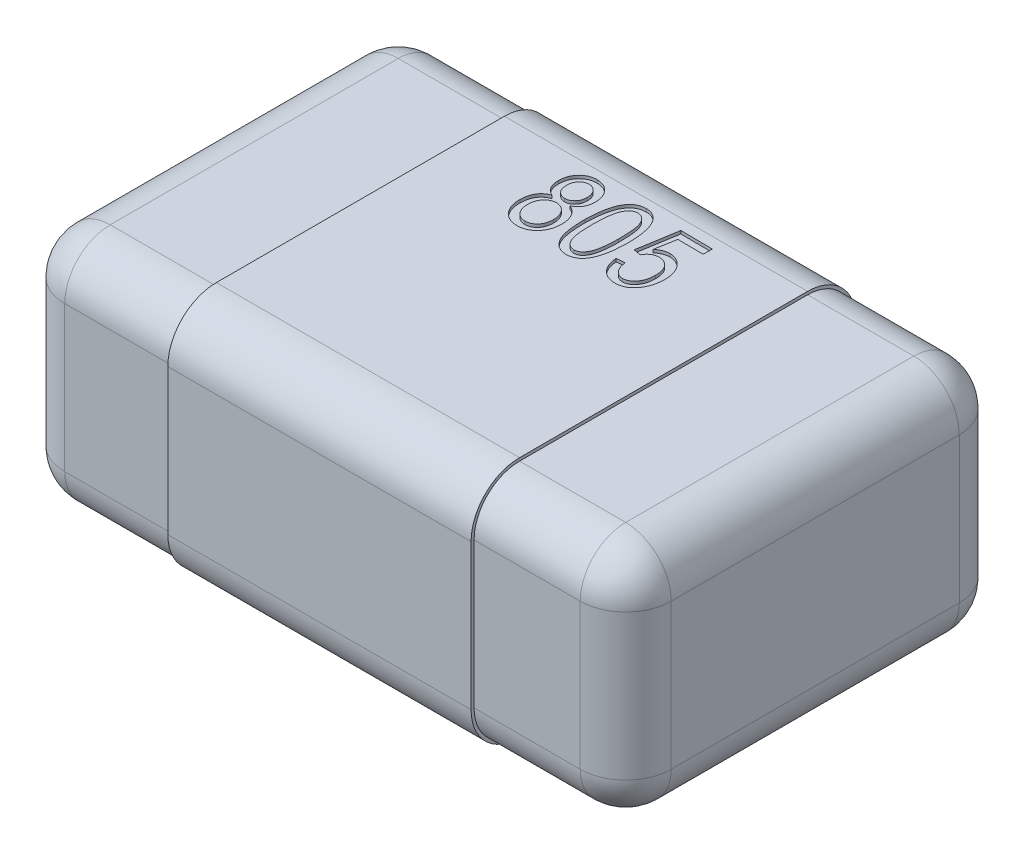
from build123d import *

# Parameters (mm, degrees)
ESBO_O1_W                     = 2
ESBO_O1_H                     = 1.25
RESSALTO_EXTRUS_O1_DEPTH      = 0.78
FILETE1_R                     = 0.15
RESSALTO_EXTRUS_O4_DEPTH      = 0.5
RESSALTO_EXTRUS_O4_DEPTH_BACK = 0.5
CORTE_EXTRUS_O1_DEPTH         = 0.01


with BuildPart() as part:
    # Esboço1 → Ressalto-extrusão1 (new body)
    with BuildSketch(Plane(origin=(0, 0.78, 0), x_dir=(1, 0, 0), z_dir=(0, 1, 0))):
        Rectangle(ESBO_O1_W, ESBO_O1_H)
    extrude(amount=-RESSALTO_EXTRUS_O1_DEPTH)

    # Filete1
    filete1_edges = [part.edges().sort_by_distance(p)[0] for p in [
        (1, 0, 0),
        (0, 0, -0.625),
        (-1, 0, 0),
        (0, 0.78, -0.625),
        (1, 0.78, 0),
        (0, 0.78, 0.625),
        (-1, 0.78, 0),
        (0, 0, 0.625),
        (-1, 0.39, -0.625),
        (1, 0.39, -0.625),
        (1, 0.39, 0.625),
        (-1, 0.39, 0.625),
    ]]
    fillet(filete1_edges, radius=FILETE1_R)

    # Esboço4 → Ressalto-extrusão4 (add, two sides)
    with BuildSketch(Plane(origin=(0, 0, 0), x_dir=(0, 0, -1), z_dir=(1, 0, 0))) as ressalto_extrus_o4_sk:
        with BuildLine():
            Line((0.635, 0.15), (0.635, 0.63))
            ThreePointArc((0.635, 0.63), (0.588137085, 0.743137085), (0.475, 0.79))
            Line((0.475, 0.79), (-0.475, 0.79))
            ThreePointArc((-0.475, 0.79), (-0.588137085, 0.743137085), (-0.635, 0.63))
            Line((-0.635, 0.63), (-0.635, 0.15))
            ThreePointArc((-0.635, 0.15), (-0.588137085, 0.036862915), (-0.475, -0.01))
            Line((-0.475, -0.01), (0.475, -0.01))
            ThreePointArc((0.475, -0.01), (0.588137085, 0.036862915), (0.635, 0.15))
        make_face()
        with BuildLine():
            Line((0.625, 0.15), (0.625, 0.63))
            ThreePointArc((0.625, 0.63), (0.581066017, 0.736066017), (0.475, 0.78))
            Line((0.475, 0.78), (-0.475, 0.78))
            ThreePointArc((-0.475, 0.78), (-0.581066017, 0.736066017), (-0.625, 0.63))
            Line((-0.625, 0.63), (-0.625, 0.15))
            ThreePointArc((-0.625, 0.15), (-0.581066017, 0.043933983), (-0.475, 0))
            Line((-0.475, 0), (0.475, 0))
            ThreePointArc((0.475, 0), (0.581066017, 0.043933983), (0.625, 0.15))
        make_face(mode=Mode.SUBTRACT)
    extrude(amount=RESSALTO_EXTRUS_O4_DEPTH)
    extrude(ressalto_extrus_o4_sk.sketch, amount=-RESSALTO_EXTRUS_O4_DEPTH_BACK)

    # Esboço2 → Corte-extrusão1 (cut)
    with BuildSketch(Plane(origin=(0, 0.79, 0), x_dir=(0, 0, 1), z_dir=(0, -1, 0))):
        with BuildLine():
            Line((-0.253066861, -0.090329898), (-0.255669833, -0.117584099))
            add(Edge.make_bspline(
                [(-0.255669833, -0.117584099), (-0.253681074, -0.117861542), (-0.249809014, -0.118401717), (-0.244214534, -0.119491466), (-0.239012719, -0.120846537), (-0.234225636, -0.122506374), (-0.229794502, -0.12432543), (-0.22576998, -0.126468531), (-0.22210853, -0.128835246), (-0.218891368, -0.131518493), (-0.216004401, -0.134334812), (-0.213518025, -0.13730113), (-0.211385032, -0.140378806), (-0.209679505, -0.143577329), (-0.20828577, -0.146879121), (-0.207291732, -0.150287825), (-0.206693548, -0.15383074), (-0.206601805, -0.15622493), (-0.206555161, -0.157442196)],
                knots=[0, 0, 0, 0, 1.38702458, 2.700499694, 3.935238579, 5.096953292, 6.198529759, 7.240644087, 8.242594165, 9.204574647, 10.129612427, 11.025542709, 11.874335218, 12.711681274, 13.525120647, 14.346138538, 15.159135127, 16, 16, 16, 16], degree=3))
            add(Edge.make_bspline(
                [(-0.206555161, -0.157442196), (-0.20659514, -0.158958341), (-0.206674321, -0.161961136), (-0.207460742, -0.166387154), (-0.208751993, -0.170659263), (-0.210549102, -0.174794271), (-0.213001017, -0.178711941), (-0.215888261, -0.182527474), (-0.219371222, -0.186133297), (-0.223293172, -0.189590506), (-0.22772585, -0.192712782), (-0.232519424, -0.195534316), (-0.237749111, -0.197864637), (-0.243353893, -0.199776731), (-0.249343489, -0.201283736), (-0.255719225, -0.202375207), (-0.262482319, -0.203072583), (-0.267129123, -0.203194089), (-0.269509575, -0.203256334)],
                knots=[0, 0, 0, 0, 0.839665796, 1.662997701, 2.482096218, 3.309247666, 4.153318297, 5.037512989, 5.956665417, 6.926897057, 7.931076711, 8.956993583, 10.005081474, 11.098198013, 12.235579651, 13.424411873, 14.680584685, 16, 16, 16, 16], degree=3))
            add(Edge.make_bspline(
                [(-0.269509575, -0.203256334), (-0.271753281, -0.20324228), (-0.276112071, -0.203214979), (-0.282457423, -0.202613172), (-0.288424533, -0.201713754), (-0.294010782, -0.200339346), (-0.29922007, -0.198574388), (-0.304023268, -0.196331862), (-0.308485604, -0.193772035), (-0.312493222, -0.190741776), (-0.316073741, -0.187447202), (-0.319208481, -0.183902384), (-0.321880479, -0.180168305), (-0.324056377, -0.176195234), (-0.325757183, -0.172027544), (-0.326968803, -0.167657526), (-0.327756799, -0.163075828), (-0.327876595, -0.159947275), (-0.327937864, -0.158347196)],
                knots=[0, 0, 0, 0, 1.301078701, 2.527572645, 3.69404768, 4.798991284, 5.860664038, 6.879371706, 7.869767973, 8.839435854, 9.787494005, 10.688249472, 11.579995176, 12.445557477, 13.310239216, 14.185371191, 15.071919164, 16, 16, 16, 16], degree=3))
            add(Edge.make_bspline(
                [(-0.327937864, -0.158347196), (-0.327875614, -0.156409781), (-0.327751398, -0.152543796), (-0.326476977, -0.146858963), (-0.324488116, -0.14133763), (-0.321634889, -0.136095193), (-0.318101728, -0.131170479), (-0.313780077, -0.126810592), (-0.308871141, -0.122912338), (-0.305196963, -0.120827116), (-0.303326113, -0.119765344)],
                knots=[0, 0, 0, 0, 0.96398326, 1.923564835, 2.888092038, 3.880191464, 4.887766155, 5.89771773, 6.92954116, 8, 8, 8, 8], degree=3))
            Line((-0.303326113, -0.119765344), (-0.307397337, -0.095389431))
            Line((-0.307397337, -0.095389431), (-0.439625822, -0.117123791))
            Line((-0.439625822, -0.117123791), (-0.438743876, -0.222139743))
            Line((-0.438743876, -0.222139743), (-0.408516123, -0.221876443))
            Line((-0.408516123, -0.221876443), (-0.409247039, -0.137603498))
            Line((-0.409247039, -0.137603498), (-0.340025673, -0.125561783))
            add(Edge.make_bspline(
                [(-0.340025673, -0.125561783), (-0.341311262, -0.127126592), (-0.3438334, -0.130196518), (-0.347086448, -0.135075395), (-0.349828763, -0.140021801), (-0.352037523, -0.145040852), (-0.353801419, -0.150082451), (-0.355025921, -0.155201424), (-0.355731626, -0.160402823), (-0.355813204, -0.16390113), (-0.355854206, -0.16565939)],
                knots=[0, 0, 0, 0, 1.102656858, 2.163251155, 3.189163745, 4.179949051, 5.146946918, 6.094910201, 7.042495509, 8, 8, 8, 8], degree=3))
            add(Edge.make_bspline(
                [(-0.355854206, -0.16565939), (-0.355760944, -0.167833298), (-0.355576404, -0.172134883), (-0.354447416, -0.178485838), (-0.35261918, -0.184606482), (-0.350099509, -0.190515981), (-0.346844388, -0.196174272), (-0.342858116, -0.201585317), (-0.338200786, -0.206796897), (-0.332881538, -0.211737158), (-0.326936504, -0.216239312), (-0.320506632, -0.220236385), (-0.313526788, -0.223481706), (-0.306131227, -0.22627122), (-0.298181016, -0.228268818), (-0.289780338, -0.229754707), (-0.280891611, -0.23059709), (-0.274805976, -0.23063847), (-0.271692966, -0.230659637)],
                knots=[0, 0, 0, 0, 0.880322538, 1.741924456, 2.603842194, 3.462077736, 4.337326652, 5.24094951, 6.178675148, 7.163753722, 8.175594835, 9.194211038, 10.222930267, 11.287579889, 12.390110003, 13.536557808, 14.739865404, 16, 16, 16, 16], degree=3))
            add(Edge.make_bspline(
                [(-0.271692966, -0.230659637), (-0.26859965, -0.230582317), (-0.262505139, -0.23042998), (-0.253549726, -0.22941805), (-0.244930876, -0.227823564), (-0.236668372, -0.225568888), (-0.228700479, -0.222815057), (-0.221139258, -0.219292778), (-0.213879389, -0.215275333), (-0.207065671, -0.210642725), (-0.200813728, -0.205536019), (-0.195317889, -0.199940945), (-0.190724738, -0.193889686), (-0.18690889, -0.187456738), (-0.184005134, -0.180580521), (-0.181913678, -0.173287056), (-0.18075483, -0.165571155), (-0.180613696, -0.160298462), (-0.180541917, -0.157616818)],
                knots=[0, 0, 0, 0, 1.138249842, 2.242601474, 3.312534934, 4.360702407, 5.391748649, 6.410873498, 7.426241692, 8.442273835, 9.438707846, 10.392558326, 11.321114167, 12.227868366, 13.137929477, 14.060125271, 15.013397121, 16, 16, 16, 16], degree=3))
            add(Edge.make_bspline(
                [(-0.180541917, -0.157616818), (-0.18062612, -0.155374401), (-0.180791873, -0.150960245), (-0.181754036, -0.144461508), (-0.183315403, -0.13823855), (-0.185468867, -0.132288804), (-0.188179186, -0.126611526), (-0.191528447, -0.121219976), (-0.195502309, -0.116123613), (-0.200010223, -0.1113099), (-0.205016941, -0.106859332), (-0.210539859, -0.102924529), (-0.216510273, -0.099536768), (-0.222932454, -0.096653099), (-0.22981884, -0.094291447), (-0.237144394, -0.092371245), (-0.244951292, -0.0910536), (-0.250312558, -0.090575511), (-0.253066861, -0.090329898)],
                knots=[0, 0, 0, 0, 0.980271121, 1.929646125, 2.86531809, 3.780208254, 4.690802838, 5.610188031, 6.548721056, 7.511035071, 8.48918643, 9.471778139, 10.469307649, 11.484938045, 12.544332569, 13.647871752, 14.791615219, 16, 16, 16, 16], degree=3))
        make_face()
        with BuildLine():
            add(Edge.make_bspline(
                [(-0.314104863, 0.07259028), (-0.31935091, 0.072485557), (-0.329517897, 0.072282602), (-0.344285374, 0.071359526), (-0.358051462, 0.069881139), (-0.370846671, 0.067914813), (-0.382646846, 0.065389513), (-0.393485951, 0.062295677), (-0.403330048, 0.058657489), (-0.412197452, 0.054502251), (-0.420024942, 0.049786263), (-0.426834217, 0.044550119), (-0.432591724, 0.038786748), (-0.437294277, 0.032499575), (-0.44092346, 0.025663429), (-0.443520045, 0.018336661), (-0.445043533, 0.010468451), (-0.445167451, 0.005066717), (-0.445231039, 0.002294821)],
                knots=[0, 0, 0, 0, 1.518955262, 2.94377781, 4.282024903, 5.526037844, 6.689929541, 7.773296542, 8.786556286, 9.725170475, 10.604166027, 11.426977307, 12.205885862, 12.955334719, 13.691502876, 14.43790793, 15.198413178, 16, 16, 16, 16], degree=3))
            add(Edge.make_bspline(
                [(-0.445231039, 0.002294821), (-0.445128975, -0.000158363), (-0.444928616, -0.004974123), (-0.443575447, -0.011976662), (-0.441428882, -0.018593213), (-0.438388656, -0.024771102), (-0.434455736, -0.030522992), (-0.429700253, -0.035861096), (-0.424110317, -0.040820856), (-0.41988693, -0.043635899), (-0.417722096, -0.04507884)],
                knots=[0, 0, 0, 0, 1.025982692, 2.014071802, 2.972641215, 3.928451672, 4.88390288, 5.878704339, 6.912661077, 8, 8, 8, 8], degree=3))
            add(Edge.make_bspline(
                [(-0.417722096, -0.04507884), (-0.414809953, -0.046782095), (-0.408765552, -0.050317346), (-0.398612163, -0.05444785), (-0.387293741, -0.057934713), (-0.374760493, -0.060750907), (-0.361024296, -0.062961633), (-0.346061433, -0.064414594), (-0.329889563, -0.065307281), (-0.318701623, -0.065309723), (-0.312913555, -0.065310986)],
                knots=[0, 0, 0, 0, 0.748520956, 1.55361904, 2.427262559, 3.377130045, 4.404196784, 5.515501031, 6.714647235, 8, 8, 8, 8], degree=3))
            add(Edge.make_bspline(
                [(-0.312913555, -0.065310986), (-0.307702286, -0.06520636), (-0.297587467, -0.065003285), (-0.2829062, -0.064087138), (-0.269193718, -0.062597586), (-0.256448556, -0.060646518), (-0.244667143, -0.058111135), (-0.233870816, -0.055017391), (-0.224012305, -0.051431802), (-0.215155147, -0.047263327), (-0.207239165, -0.042645284), (-0.200466825, -0.037353692), (-0.194610138, -0.031688775), (-0.189933803, -0.025350248), (-0.186232539, -0.018529856), (-0.183730507, -0.011129697), (-0.182112569, -0.003269141), (-0.18200023, 0.002156221), (-0.181942803, 0.004929654)],
                knots=[0, 0, 0, 0, 1.510675215, 2.932146934, 4.26194187, 5.507420904, 6.667745466, 7.752389235, 8.760424529, 9.704733944, 10.586607384, 11.410388362, 12.190344917, 12.940677014, 13.684561089, 14.430096408, 15.197468493, 16, 16, 16, 16], degree=3))
            add(Edge.make_bspline(
                [(-0.181942803, 0.004929654), (-0.182060389, 0.007400534), (-0.1822923, 0.01227373), (-0.183747611, 0.019391564), (-0.186112235, 0.026146406), (-0.18947362, 0.032521974), (-0.193711095, 0.03857621), (-0.198920982, 0.04423301), (-0.205027283, 0.049517677), (-0.212041365, 0.054511632), (-0.220234399, 0.059014444), (-0.229773323, 0.062725335), (-0.240547062, 0.066017527), (-0.252717679, 0.068474351), (-0.266179321, 0.070492429), (-0.280981489, 0.071789015), (-0.297097172, 0.072566277), (-0.308282319, 0.072582062), (-0.314104863, 0.07259028)],
                knots=[0, 0, 0, 0, 0.717108278, 1.414318207, 2.099927537, 2.787665662, 3.499472101, 4.238938378, 5.013596833, 5.839526143, 6.733835186, 7.71898771, 8.804858916, 9.999838471, 11.318634348, 12.754073451, 14.310299461, 16, 16, 16, 16], degree=3))
        make_face()
        with BuildLine():
            add(Edge.make_bspline(
                [(-0.313852677, 0.046011062), (-0.308830726, 0.046023772), (-0.299216679, 0.046048104), (-0.285440773, 0.045611416), (-0.272958114, 0.044812606), (-0.261767753, 0.04362379), (-0.251864025, 0.042060045), (-0.243236052, 0.040090326), (-0.235864256, 0.037794199), (-0.229714882, 0.034971535), (-0.22461724, 0.031823137), (-0.220201965, 0.028545509), (-0.216468896, 0.025014509), (-0.213409547, 0.021245308), (-0.210986674, 0.017282422), (-0.20929673, 0.013065823), (-0.208167486, 0.008644765), (-0.208049458, 0.005595108), (-0.207990092, 0.004061192)],
                knots=[0, 0, 0, 0, 1.925404163, 3.686002627, 5.283513051, 6.720238148, 7.99934928, 9.125350353, 10.111158045, 10.954250683, 11.711863435, 12.404721246, 13.059420021, 13.676332432, 14.261276038, 14.832753221, 15.412898692, 16, 16, 16, 16], degree=3))
            add(Edge.make_bspline(
                [(-0.207990092, 0.004061192), (-0.208037257, 0.00261167), (-0.208131114, -0.000272886), (-0.209156544, -0.004512793), (-0.210797821, -0.008582769), (-0.213201253, -0.012432197), (-0.216254038, -0.016077629), (-0.219919351, -0.019625619), (-0.224337535, -0.022904377), (-0.229464873, -0.026073683), (-0.235579212, -0.029012681), (-0.242946009, -0.031401217), (-0.251535407, -0.033507352), (-0.261392145, -0.035279694), (-0.272525818, -0.036623526), (-0.284922219, -0.037650947), (-0.298590691, -0.038369282), (-0.308130577, -0.038504086), (-0.313116341, -0.038574538)],
                knots=[0, 0, 0, 0, 0.559707278, 1.11382018, 1.676745117, 2.250868501, 2.860911027, 3.512297026, 4.219262167, 4.984471586, 5.841451888, 6.835998971, 7.973757443, 9.260733032, 10.707010167, 12.309886215, 14.071461385, 16, 16, 16, 16], degree=3))
            add(Edge.make_bspline(
                [(-0.313116341, -0.038574538), (-0.318138121, -0.038584645), (-0.32776919, -0.038604029), (-0.341566163, -0.038199893), (-0.354077939, -0.037303331), (-0.365290558, -0.036147486), (-0.375207669, -0.03456514), (-0.383850893, -0.032623577), (-0.391198706, -0.030239664), (-0.397354361, -0.027452399), (-0.402412205, -0.024266066), (-0.406823515, -0.021008453), (-0.410549064, -0.017471531), (-0.413648688, -0.013691247), (-0.416017272, -0.00964333), (-0.417751709, -0.005378068), (-0.418780029, -0.000867799), (-0.418951434, 0.002224743), (-0.419038261, 0.003791301)],
                knots=[0, 0, 0, 0, 1.919766241, 3.681842716, 5.275242921, 6.714350395, 7.989716066, 9.11242001, 10.097515071, 10.938138986, 11.687936314, 12.378765315, 13.031547017, 13.646653001, 14.241416236, 14.817417711, 15.400950926, 16, 16, 16, 16], degree=3))
            add(Edge.make_bspline(
                [(-0.419038261, 0.003791301), (-0.418991916, 0.005240916), (-0.418900228, 0.008108779), (-0.417879461, 0.012300269), (-0.416211212, 0.016320561), (-0.413759119, 0.020092637), (-0.410793474, 0.023809936), (-0.407045472, 0.027249975), (-0.402621561, 0.030493679), (-0.397520263, 0.033678232), (-0.391375973, 0.036537542), (-0.384027044, 0.038944148), (-0.375423782, 0.041067989), (-0.365552695, 0.042739599), (-0.354428312, 0.044119903), (-0.3420486, 0.045153137), (-0.32837692, 0.045786884), (-0.318838152, 0.045934112), (-0.313852677, 0.046011062)],
                knots=[0, 0, 0, 0, 0.560659339, 1.109187153, 1.660721523, 2.239473205, 2.846200591, 3.499111083, 4.203333159, 4.969844199, 5.825506881, 6.821745687, 7.961439487, 9.256180113, 10.69822505, 12.30382759, 14.068180942, 16, 16, 16, 16], degree=3))
        make_face(mode=Mode.SUBTRACT)
        with BuildLine():
            add(Edge.make_bspline(
                [(-0.327858331, 0.195985511), (-0.329099911, 0.19845275), (-0.331530494, 0.203282744), (-0.33627748, 0.20971924), (-0.341810954, 0.215176818), (-0.348107412, 0.219667619), (-0.355210512, 0.22309761), (-0.363054072, 0.225592832), (-0.371720149, 0.226999915), (-0.377753479, 0.227115244), (-0.380888483, 0.227175171)],
                knots=[0, 0, 0, 0, 1.010375038, 1.977962205, 2.913937957, 3.846858604, 4.797409045, 5.791501307, 6.852432789, 8, 8, 8, 8], degree=3))
            add(Edge.make_bspline(
                [(-0.380888483, 0.227175171), (-0.383286733, 0.22710216), (-0.387973584, 0.226959475), (-0.394816784, 0.226110148), (-0.401320978, 0.22469464), (-0.407466443, 0.222696372), (-0.413318071, 0.220272432), (-0.418780054, 0.217224096), (-0.423888931, 0.213621333), (-0.428640697, 0.20954804), (-0.432942517, 0.205079747), (-0.436614246, 0.2002227), (-0.43978224, 0.195158086), (-0.442393484, 0.189816795), (-0.444291593, 0.184161753), (-0.445746338, 0.178270211), (-0.446502644, 0.172079016), (-0.446598542, 0.167867489), (-0.446647279, 0.165727146)],
                knots=[0, 0, 0, 0, 1.1412269, 2.23027706, 3.275921697, 4.303637785, 5.301396255, 6.285084571, 7.273243197, 8.271309802, 9.259157202, 10.218367275, 11.163041661, 12.098338492, 13.039752248, 13.996108583, 14.981601324, 16, 16, 16, 16], degree=3))
            add(Edge.make_bspline(
                [(-0.446647279, 0.165727146), (-0.44658758, 0.163570688), (-0.446470104, 0.15932719), (-0.445488997, 0.153129796), (-0.443999278, 0.147205365), (-0.441841962, 0.14158956), (-0.439131276, 0.136238074), (-0.435855587, 0.1311688), (-0.431980153, 0.126395921), (-0.427529235, 0.12197801), (-0.422665385, 0.117917069), (-0.417411004, 0.114366442), (-0.411772896, 0.111458966), (-0.405849286, 0.108950529), (-0.399512287, 0.107193779), (-0.392898085, 0.105810272), (-0.385936651, 0.10504091), (-0.381188473, 0.105000218), (-0.378770525, 0.104979496)],
                knots=[0, 0, 0, 0, 1.013788584, 1.9949429, 2.944310882, 3.882607036, 4.818195054, 5.761459528, 6.716087984, 7.704294713, 8.70672387, 9.692799856, 10.680161602, 11.686612657, 12.712741619, 13.767462072, 14.863108828, 16, 16, 16, 16], degree=3))
            add(Edge.make_bspline(
                [(-0.378770525, 0.104979496), (-0.375779175, 0.105099293), (-0.370006008, 0.105330495), (-0.361690634, 0.106823152), (-0.354118261, 0.10935816), (-0.347256858, 0.112848743), (-0.341068303, 0.117274355), (-0.335685575, 0.122758022), (-0.330937668, 0.129166221), (-0.328568498, 0.134020951), (-0.327348892, 0.136520077)],
                knots=[0, 0, 0, 0, 1.119279744, 2.160158041, 3.149011654, 4.096757587, 5.030828695, 5.982401223, 6.961377217, 8, 8, 8, 8], degree=3))
            add(Edge.make_bspline(
                [(-0.327348892, 0.136520077), (-0.326688867, 0.134955526), (-0.325388188, 0.131872344), (-0.322986498, 0.127512033), (-0.320298948, 0.12344374), (-0.31738237, 0.119606626), (-0.314108231, 0.116123849), (-0.310603395, 0.112869774), (-0.306779607, 0.109909593), (-0.30267539, 0.107220805), (-0.298291503, 0.104842754), (-0.293653725, 0.102781457), (-0.288759589, 0.101047765), (-0.28362081, 0.099604125), (-0.278222221, 0.09859949), (-0.272598275, 0.097767212), (-0.266718413, 0.097370646), (-0.262713673, 0.097344429), (-0.260679799, 0.097331114)],
                knots=[0, 0, 0, 0, 0.985697917, 1.942466207, 2.885786514, 3.816066401, 4.737771084, 5.658370606, 6.591218596, 7.542705401, 8.505096483, 9.484630005, 10.487224198, 11.518400315, 12.58108184, 13.674221563, 14.818814401, 16, 16, 16, 16], degree=3))
            add(Edge.make_bspline(
                [(-0.260679799, 0.097331114), (-0.257865051, 0.097426393), (-0.252361434, 0.09761269), (-0.244312608, 0.098566506), (-0.236674602, 0.100239268), (-0.229419789, 0.102462122), (-0.222599251, 0.105394003), (-0.216139208, 0.108815823), (-0.210143633, 0.112986221), (-0.204576508, 0.117696542), (-0.199540674, 0.122838103), (-0.19515029, 0.128347093), (-0.191429427, 0.134127273), (-0.188453952, 0.140247717), (-0.186063983, 0.146609598), (-0.184508056, 0.153316934), (-0.183463417, 0.160292496), (-0.183418585, 0.165054729), (-0.183395798, 0.167475223)],
                knots=[0, 0, 0, 0, 1.156965278, 2.262190252, 3.324751649, 4.366096493, 5.374855877, 6.370957931, 7.364832225, 8.369339493, 9.363726357, 10.317011746, 11.259410688, 12.182056031, 13.108669284, 14.045346394, 15.006510308, 16, 16, 16, 16], degree=3))
            add(Edge.make_bspline(
                [(-0.183395798, 0.167475223), (-0.183467883, 0.169927868), (-0.183609116, 0.174733231), (-0.184793224, 0.18175928), (-0.186494453, 0.188479961), (-0.188903217, 0.194903987), (-0.19207763, 0.200980517), (-0.195873711, 0.206753057), (-0.200353048, 0.21221364), (-0.205466009, 0.217276759), (-0.21109789, 0.221939766), (-0.217247574, 0.225946821), (-0.223787225, 0.229365841), (-0.230802042, 0.23202921), (-0.238176641, 0.234236624), (-0.246014649, 0.235676564), (-0.25425695, 0.236555333), (-0.259893519, 0.236600718), (-0.262781346, 0.23662397)],
                knots=[0, 0, 0, 0, 0.996806511, 1.953000566, 2.890346446, 3.813283352, 4.735895699, 5.672788825, 6.618405564, 7.602689611, 8.595079679, 9.586639473, 10.582418904, 11.590033247, 12.633590743, 13.708834414, 14.826149628, 16, 16, 16, 16], degree=3))
            add(Edge.make_bspline(
                [(-0.262781346, 0.23662397), (-0.264883533, 0.236575209), (-0.269005551, 0.236479598), (-0.275055315, 0.235958408), (-0.280827184, 0.235099534), (-0.28629145, 0.233818899), (-0.291496178, 0.232366685), (-0.296396576, 0.230492672), (-0.301001603, 0.228264418), (-0.305344478, 0.225750411), (-0.309359401, 0.2229233), (-0.313024646, 0.219811003), (-0.316375685, 0.216479521), (-0.319326152, 0.212854379), (-0.322016202, 0.209031759), (-0.324319135, 0.204934665), (-0.326319036, 0.200580431), (-0.327339376, 0.197534634), (-0.327858331, 0.195985511)],
                knots=[0, 0, 0, 0, 1.222081605, 2.396286442, 3.527405086, 4.610768873, 5.6567772, 6.66622004, 7.655766911, 8.627793693, 9.580106589, 10.505921941, 11.420042547, 12.322599357, 13.21948892, 14.133944144, 15.050905111, 16, 16, 16, 16], degree=3))
        make_face()
        with BuildLine():
            add(Edge.make_bspline(
                [(-0.38157155, 0.200423369), (-0.380023799, 0.200398897), (-0.377008371, 0.200351219), (-0.372586385, 0.199976261), (-0.368420018, 0.199223663), (-0.364509426, 0.198113265), (-0.360795526, 0.196795999), (-0.357356498, 0.195078118), (-0.354125737, 0.193080303), (-0.351206652, 0.190744222), (-0.348553871, 0.188181472), (-0.346213331, 0.185470092), (-0.344205048, 0.182616425), (-0.342577652, 0.179600571), (-0.341326378, 0.176435532), (-0.34042303, 0.173131048), (-0.339896878, 0.169675903), (-0.339797141, 0.167319852), (-0.33974637, 0.166120517)],
                knots=[0, 0, 0, 0, 1.225964966, 2.388504465, 3.511185861, 4.573549014, 5.605990611, 6.627646103, 7.612398978, 8.609667768, 9.582717129, 10.530629034, 11.442807668, 12.341391226, 13.238498409, 14.132963151, 15.049594242, 16, 16, 16, 16], degree=3))
            add(Edge.make_bspline(
                [(-0.33974637, 0.166120517), (-0.33984265, 0.163824155), (-0.340032295, 0.15930095), (-0.342192324, 0.152809686), (-0.345646123, 0.146837019), (-0.35049576, 0.141578496), (-0.356396245, 0.137156499), (-0.363237828, 0.133830369), (-0.370967339, 0.131941692), (-0.376374793, 0.131653369), (-0.379178134, 0.131503896)],
                knots=[0, 0, 0, 0, 0.938791819, 1.849163316, 2.77304386, 3.7510156, 4.761620007, 5.781875391, 6.850076016, 8, 8, 8, 8], degree=3))
            add(Edge.make_bspline(
                [(-0.379178134, 0.131503896), (-0.380656814, 0.131524685), (-0.383553718, 0.131565414), (-0.387782446, 0.132014999), (-0.391802244, 0.132793146), (-0.395642815, 0.133845147), (-0.399254573, 0.135329402), (-0.402720053, 0.137022149), (-0.405936285, 0.139128275), (-0.4098613, 0.14226038), (-0.414101761, 0.146614974), (-0.417817825, 0.15255718), (-0.420233976, 0.159002313), (-0.420536919, 0.163519659), (-0.42069066, 0.165812167)],
                knots=[0, 0, 0, 0, 0.888699731, 1.741064503, 2.55218699, 3.348448891, 4.13012588, 4.896229071, 5.663825711, 6.435390751, 7.913538787, 9.290884697, 10.625150828, 12, 12, 12, 12], degree=3))
            add(Edge.make_bspline(
                [(-0.42069066, 0.165812167), (-0.420577064, 0.168092655), (-0.420353104, 0.172588721), (-0.418124682, 0.179038963), (-0.414616904, 0.185003404), (-0.409731204, 0.1903003), (-0.40382886, 0.194775617), (-0.397013667, 0.197994955), (-0.389518713, 0.200009627), (-0.384273582, 0.200282697), (-0.38157155, 0.200423369)],
                knots=[0, 0, 0, 0, 0.940152606, 1.853545198, 2.788743803, 3.784900211, 4.813833144, 5.832937449, 6.883636414, 8, 8, 8, 8], degree=3))
        make_face(mode=Mode.SUBTRACT)
        with BuildLine():
            add(Edge.make_bspline(
                [(-0.262530063, 0.210096861), (-0.260599382, 0.210069871), (-0.256815091, 0.21001697), (-0.251278115, 0.20949184), (-0.24602448, 0.208554317), (-0.241075892, 0.207154156), (-0.23638297, 0.20543808), (-0.232010444, 0.203250412), (-0.227904473, 0.200701149), (-0.224141175, 0.197751565), (-0.220708736, 0.194557342), (-0.217713262, 0.19115464), (-0.215155269, 0.187580347), (-0.213151271, 0.183804562), (-0.211454559, 0.17993203), (-0.210305634, 0.175866568), (-0.209595567, 0.171628446), (-0.209467571, 0.168745671), (-0.20940272, 0.167285081)],
                knots=[0, 0, 0, 0, 1.217090807, 2.385596887, 3.502656925, 4.577010867, 5.624562514, 6.648482137, 7.654134486, 8.666860819, 9.658395309, 10.606505315, 11.520989575, 12.422457717, 13.297107112, 14.181917277, 15.078848695, 16, 16, 16, 16], degree=3))
            add(Edge.make_bspline(
                [(-0.20940272, 0.167285081), (-0.209434714, 0.165822663), (-0.2094979, 0.162934531), (-0.210106529, 0.158670339), (-0.211191297, 0.154584067), (-0.212692083, 0.150648253), (-0.21468908, 0.146908678), (-0.21707388, 0.143311197), (-0.219920689, 0.139895238), (-0.223187883, 0.13668664), (-0.226800394, 0.133719496), (-0.230747209, 0.131113847), (-0.235037552, 0.128979963), (-0.239563861, 0.127090659), (-0.244449242, 0.125736363), (-0.249602002, 0.124692874), (-0.255069462, 0.124090589), (-0.258812421, 0.123973652), (-0.260723548, 0.123913945)],
                knots=[0, 0, 0, 0, 0.933767324, 1.844097433, 2.743404377, 3.62946927, 4.528365353, 5.445635132, 6.38203613, 7.363131963, 8.36656495, 9.364028548, 10.376440843, 11.423295474, 12.491919467, 13.608497015, 14.778916073, 16, 16, 16, 16], degree=3))
            add(Edge.make_bspline(
                [(-0.260723548, 0.123913945), (-0.262654178, 0.123941064), (-0.266438369, 0.12399422), (-0.271976066, 0.124517525), (-0.27722713, 0.125461548), (-0.282191023, 0.12684045), (-0.286857044, 0.128642167), (-0.291263453, 0.130798316), (-0.295331566, 0.133425721), (-0.299136336, 0.136356585), (-0.302527212, 0.139613112), (-0.305564119, 0.143014361), (-0.308084101, 0.146633812), (-0.310121227, 0.150424771), (-0.311802023, 0.154341587), (-0.312947378, 0.158440861), (-0.313667261, 0.162712032), (-0.31379309, 0.165612417), (-0.313857214, 0.167090488)],
                knots=[0, 0, 0, 0, 1.212658758, 2.376909712, 3.489901964, 4.560343636, 5.608124024, 6.628315032, 7.636290558, 8.645329037, 9.640879394, 10.585536848, 11.50573155, 12.403916987, 13.285505108, 14.177636265, 15.071301498, 16, 16, 16, 16], degree=3))
            add(Edge.make_bspline(
                [(-0.313857214, 0.167090488), (-0.313832218, 0.168553941), (-0.313783098, 0.171429841), (-0.313081449, 0.175648665), (-0.312019251, 0.179713696), (-0.310468803, 0.183615869), (-0.308408117, 0.187314789), (-0.305960334, 0.190885744), (-0.303017185, 0.194258517), (-0.299721887, 0.197493947), (-0.296018735, 0.200399029), (-0.292038246, 0.203007116), (-0.28774425, 0.205146319), (-0.283198278, 0.206901978), (-0.278407245, 0.208283448), (-0.273355813, 0.209317588), (-0.268028439, 0.209924181), (-0.264389215, 0.210038473), (-0.262530063, 0.210096861)],
                knots=[0, 0, 0, 0, 0.939382784, 1.846024343, 2.740000466, 3.635647833, 4.535667455, 5.455748548, 6.412482529, 7.407589067, 8.419029771, 9.43194793, 10.460493566, 11.495320456, 12.559594207, 13.660927229, 14.80505007, 16, 16, 16, 16], degree=3))
        make_face(mode=Mode.SUBTRACT)
    extrude(amount=CORTE_EXTRUS_O1_DEPTH, mode=Mode.SUBTRACT)


solid = part.part
